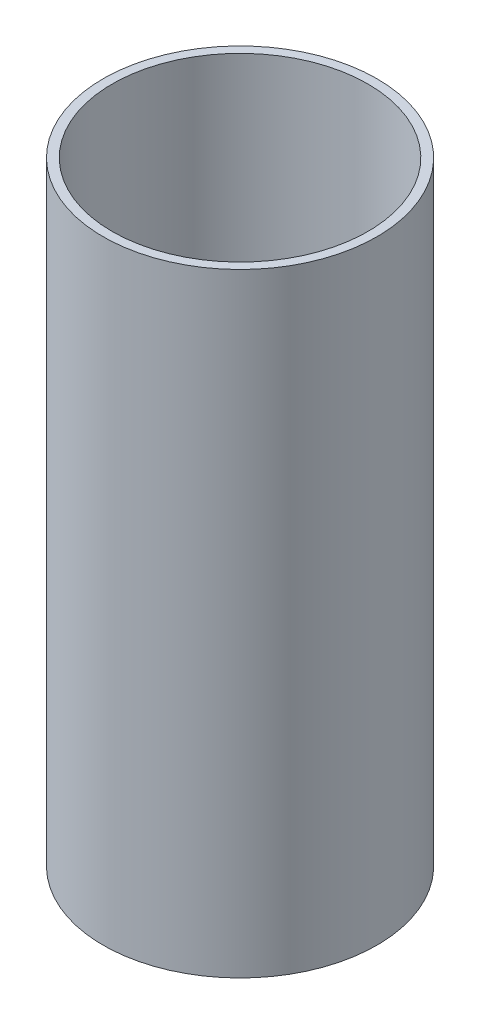
from build123d import *

# Parameters (mm, degrees)
SKETCH1_W = 1.8034
SKETCH1_H = 122.1486


with BuildPart() as part:
    # Sketch1 → Revolve1 (revolve)
    with BuildSketch(Plane.XY):
        with Locations((26.3525, 61.0743)):
            Rectangle(SKETCH1_W, SKETCH1_H)
    revolve(axis=Axis((0, -8.89, 0), (0, 1, 0)))


solid = part.part
